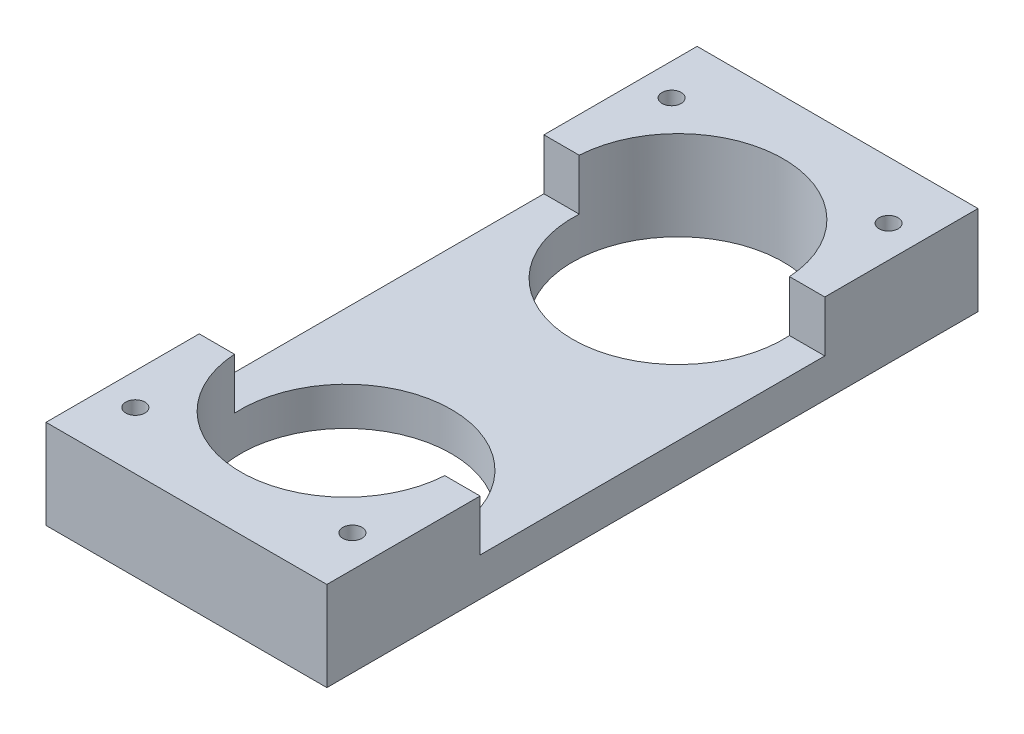
from build123d import *

# Parameters (mm, degrees)
SKETCH_1_W             = 22
SKETCH_1_H             = 51
EXTRUDE_410_DEPTH      = 3
SKETCH_2_W             = 22
SKETCH_2_H             = 12
EXTRUDE_754_DEPTH      = 4
SKETCH_3_R             = 8.25
CUT_EXTRUDE_970_DEPTH  = 8
SKETCH_4_R             = 0.75
CUT_EXTRUDE_1248_DEPTH = 8


with BuildPart() as part:
    # 草图1 → Extrude 410 (new body)
    with BuildSketch(Plane(origin=(0, 0, 0), x_dir=(1, 0, 0), z_dir=(0, 1, 0))):
        Rectangle(SKETCH_1_W, SKETCH_1_H)
    extrude(amount=EXTRUDE_410_DEPTH)

    # 草图2 → Extrude 754 (add)
    with BuildSketch(Plane(origin=(0, 3, 0), x_dir=(1, 0, 0), z_dir=(0, 1, 0))):
        with Locations((0, -19.5)):
            Rectangle(SKETCH_2_W, SKETCH_2_H)
        with Locations((0, 19.5)):
            Rectangle(SKETCH_2_W, SKETCH_2_H)
    extrude(amount=EXTRUDE_754_DEPTH)

    # 草图3 → Cut-Extrude 970 (cut, through all)
    with BuildSketch(Plane.XZ):
        with Locations((0, 13)):
            Circle(SKETCH_3_R)
        with Locations((0, -13)):
            Circle(SKETCH_3_R)
    extrude(amount=-CUT_EXTRUDE_970_DEPTH, mode=Mode.SUBTRACT)

    # 草图4 → Cut-Extrude 1248 (cut, through all)
    with BuildSketch(Plane(origin=(0, 7, 0), x_dir=(1, 0, 0), z_dir=(0, 1, 0))):
        with Locations((-8.5, -21)):
            Circle(SKETCH_4_R)
        with Locations((8.5, -21)):
            Circle(SKETCH_4_R)
        with Locations((8.5, 21)):
            Circle(SKETCH_4_R)
        with Locations((-8.5, 21)):
            Circle(SKETCH_4_R)
    extrude(amount=-CUT_EXTRUDE_1248_DEPTH, mode=Mode.SUBTRACT)


solid = part.part
